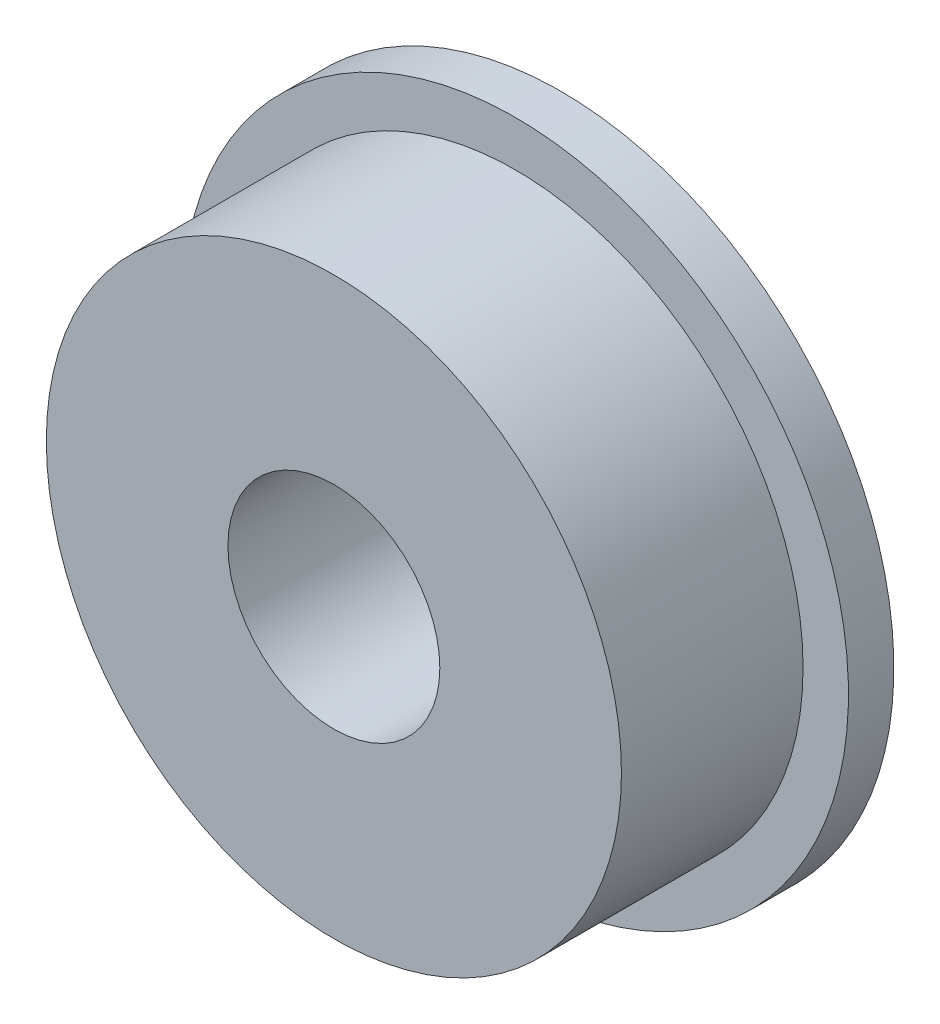
from build123d import *

# Parameters (mm, degrees)
SKETCH_1_R      = 9.5
SKETCH_1_R_2    = 3.5
EXTRUDE_1_DEPTH = 6
SKETCH_2_R      = 11
SKETCH_2_R_2    = 3.5
EXTRUDE_2_DEPTH = 1.5


with BuildPart() as part:
    # 草圖1 → 填料-伸長1 (new body)
    with BuildSketch(Plane.XY):
        Circle(SKETCH_1_R)
        Circle(SKETCH_1_R_2, mode=Mode.SUBTRACT)
    extrude(amount=EXTRUDE_1_DEPTH)

    # 草圖2 → 填料-伸長2 (add)
    with BuildSketch(Plane(origin=(0, 0, 0), x_dir=(-1, 0, 0), z_dir=(0, 0, -1))):
        Circle(SKETCH_2_R)
        Circle(SKETCH_2_R_2, mode=Mode.SUBTRACT)
    extrude(amount=EXTRUDE_2_DEPTH)


solid = part.part
